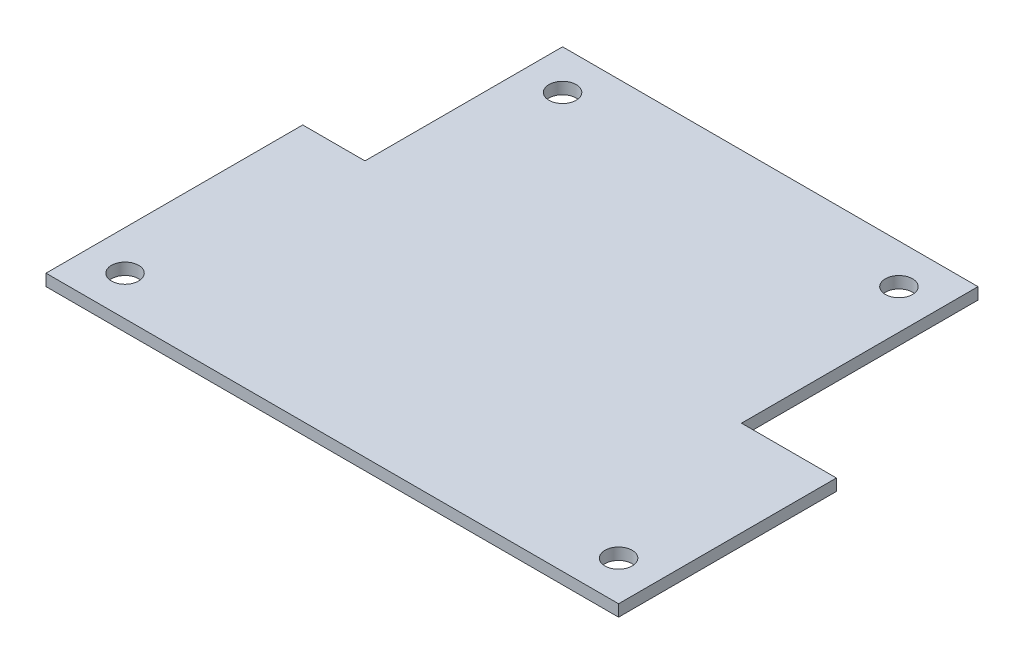
from build123d import *

# Parameters (mm, degrees)
SKETCH1_R           = 1.75
BOSS_EXTRUDE1_DEPTH = 1.5


with BuildPart() as part:
    # Sketch1 → Boss-Extrude1 (new body)
    with BuildSketch(Plane(origin=(0, 0, 0), x_dir=(1, 0, 0), z_dir=(0, 1, 0))):
        Polygon((0, 0), (73.6, 0), (73.6, 28), (61.4, 28), (61.4, 58.4), (8, 58.4), (8, 33), (0, 33), align=None)
        with Locations((5.08, 5.08)):
            Circle(SKETCH1_R, mode=Mode.SUBTRACT)
        with Locations((68.52, 5.08)):
            Circle(SKETCH1_R, mode=Mode.SUBTRACT)
        with Locations((13.08, 53.32)):
            Circle(SKETCH1_R, mode=Mode.SUBTRACT)
        with Locations((56.32, 53.32)):
            Circle(SKETCH1_R, mode=Mode.SUBTRACT)
    extrude(amount=BOSS_EXTRUDE1_DEPTH)


solid = part.part
